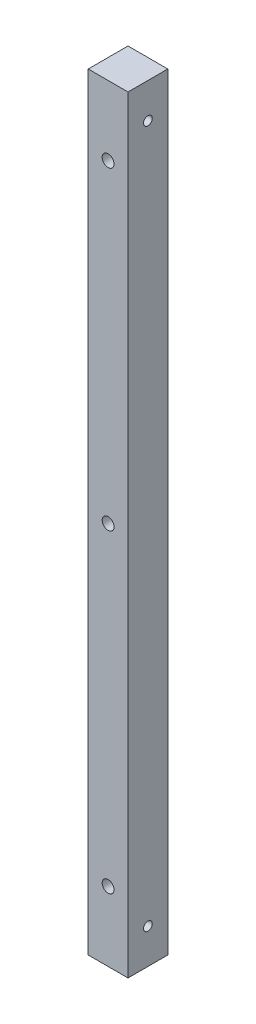
from build123d import *

# Parameters (mm, degrees)
ESQUISSE1_W        = 11.4
ESQUISSE1_H        = 11.4
BOSS_EXTRU_1_DEPTH = 219.772
D_GAGEMENT_M31_D   = 3.4
TROU_TARAUD_M31_D  = 2.5


with BuildPart() as part:
    # Esquisse1 → Boss.-Extru.1 (new body)
    with BuildSketch(Plane(origin=(0, 0, 0), x_dir=(1, 0, 0), z_dir=(0, 1, 0))):
        Rectangle(ESQUISSE1_W, ESQUISSE1_H)
    extrude(amount=BOSS_EXTRU_1_DEPTH)

    # Dégagement M31 (through all)
    with Locations(Plane.XY.offset(5.7)):
        with Locations((0, 199.885), (0, 109.885), (0, 19.885)):
            Hole(D_GAGEMENT_M31_D / 2)

    # Trou taraudé M31 (through all)
    with Locations(Plane(origin=(5.7, 0, 0), x_dir=(0, 0, -1), z_dir=(1, 0, 0))):
        with Locations((0, 209.772), (0, 10)):
            Hole(TROU_TARAUD_M31_D / 2)


solid = part.part
